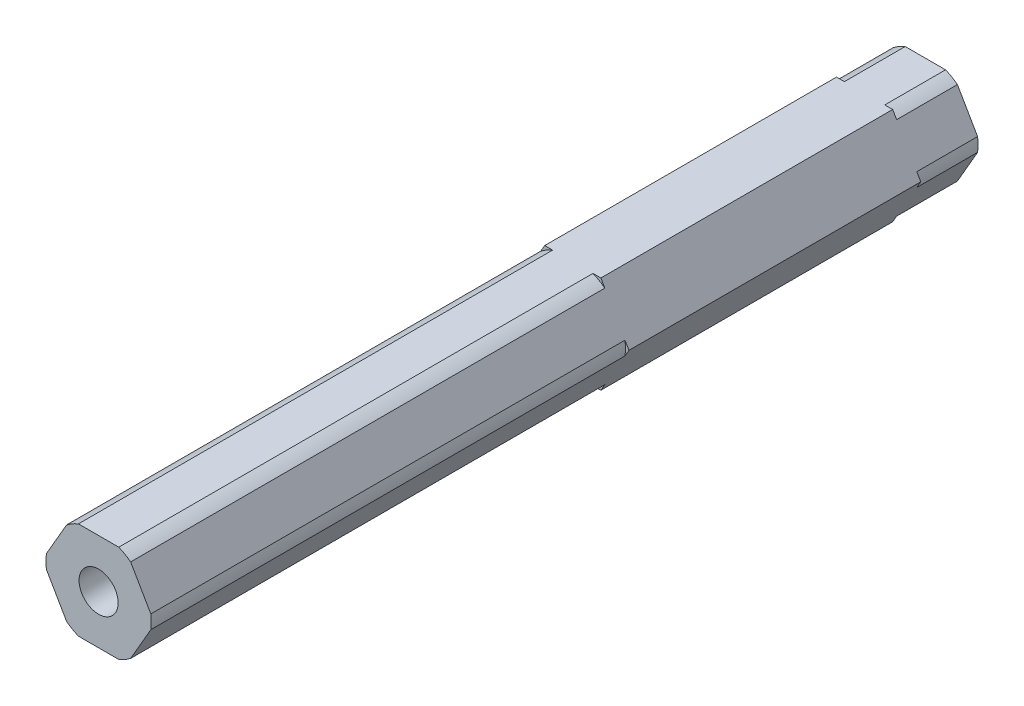
from build123d import *

# Parameters (mm, degrees)
BOSS_EXTRUDE1_DEPTH         = 19.05
BOSS_EXTRUDE2_DEPTH         = 7.9375
BOSS_EXTRUDE3_DEPTH         = 53.975
SKETCH6_R                   = 3.175
CUT_EXTRUDE1_DEPTH          = 11.811
F_10_32_TAPPED_HOLE1_D      = 4.0386
F_10_32_TAPPED_HOLE1_DEPTH  = 12.0396
F_10_32_TAPPED_HOLE1_TIP    = 1.213317848
F_1_4_20_TAPPED_HOLE1_D     = 5.1054
F_1_4_20_TAPPED_HOLE1_DEPTH = 19.05
F_1_4_20_TAPPED_HOLE1_TIP   = 1.533816902


with BuildPart() as part:
    # Sketch1 → Boss-Extrude1 (new body, symmetric)
    with BuildSketch(Plane.XY):
        Polygon((-7.332348419, 0), (-3.666174209, -6.35), (3.666174209, -6.35), (7.332348419, 0), (3.666174209, 6.35), (-3.666174209, 6.35), align=None)
    extrude(amount=BOSS_EXTRUDE1_DEPTH, both=True)

    # Sketch2 → Boss-Extrude2 (add)
    with BuildSketch(Plane.XY.offset(19.05)):
        with BuildLine():
            Line((6.816751826, 0.893039494), (4.181770802, 5.456960506))
            ThreePointArc((4.181770802, 5.456960506), (3.4375, 5.953924651), (2.634981025, 6.35))
            Line((2.634981025, 6.35), (-2.634981025, 6.35))
            ThreePointArc((-2.634981025, 6.35), (-3.4375, 5.953924651), (-4.181770802, 5.456960506))
            Line((-4.181770802, 5.456960506), (-6.816751826, 0.893039494))
            ThreePointArc((-6.816751826, 0.893039494), (-6.875, 0), (-6.816751826, -0.893039494))
            Line((-6.816751826, -0.893039494), (-4.181770802, -5.456960506))
            ThreePointArc((-4.181770802, -5.456960506), (-3.4375, -5.953924651), (-2.634981025, -6.35))
            Line((-2.634981025, -6.35), (2.634981025, -6.35))
            ThreePointArc((2.634981025, -6.35), (3.4375, -5.953924651), (4.181770802, -5.456960506))
            Line((4.181770802, -5.456960506), (6.816751826, -0.893039494))
            ThreePointArc((6.816751826, -0.893039494), (6.875, 0), (6.816751826, 0.893039494))
        make_face()
    boss_extrude2 = extrude(amount=BOSS_EXTRUDE2_DEPTH)

    # Mirror1: Boss-Extrude2 across plane
    add(boss_extrude2.mirror(Plane.XY))

    # Sketch3 → Boss-Extrude3 (add)
    with BuildSketch(Plane.XY.offset(26.9875)):
        with BuildLine():
            Line((6.816751826, 0.893039494), (4.181770802, 5.456960506))
            ThreePointArc((4.181770802, 5.456960506), (3.4375, 5.953924651), (2.634981025, 6.35))
            Line((2.634981025, 6.35), (-2.634981025, 6.35))
            ThreePointArc((-2.634981025, 6.35), (-3.4375, 5.953924651), (-4.181770802, 5.456960506))
            Line((-4.181770802, 5.456960506), (-6.816751826, 0.893039494))
            ThreePointArc((-6.816751826, 0.893039494), (-6.875, 0), (-6.816751826, -0.893039494))
            Line((-6.816751826, -0.893039494), (-4.181770802, -5.456960506))
            ThreePointArc((-4.181770802, -5.456960506), (-3.4375, -5.953924651), (-2.634981025, -6.35))
            Line((-2.634981025, -6.35), (2.634981025, -6.35))
            ThreePointArc((2.634981025, -6.35), (3.4375, -5.953924651), (4.181770802, -5.456960506))
            Line((4.181770802, -5.456960506), (6.816751826, -0.893039494))
            ThreePointArc((6.816751826, -0.893039494), (6.875, 0), (6.816751826, 0.893039494))
        make_face()
    extrude(amount=BOSS_EXTRUDE3_DEPTH)

    # Sketch6 → Cut-Extrude1 (cut)
    with BuildSketch(Plane(origin=(0, 0, -26.9875), x_dir=(-1, 0, 0), z_dir=(0, 0, -1))):
        Circle(SKETCH6_R)
    extrude(amount=-CUT_EXTRUDE1_DEPTH, mode=Mode.SUBTRACT)

    # #10-32 Tapped Hole1
    with Locations(Plane(origin=(0, 0, -15.1765), x_dir=(-1, 0, 0), z_dir=(0, 0, -1))):
        with Locations((0, 0)):
            Hole(F_10_32_TAPPED_HOLE1_D / 2, depth=F_10_32_TAPPED_HOLE1_DEPTH)
            with Locations((0, 0, -(F_10_32_TAPPED_HOLE1_DEPTH + F_10_32_TAPPED_HOLE1_TIP / 2))):  # 118° drill point
                Cone(0, F_10_32_TAPPED_HOLE1_D / 2, F_10_32_TAPPED_HOLE1_TIP, mode=Mode.SUBTRACT)

    # 1/4-20 Tapped Hole1
    with Locations(Plane.XY.offset(80.9625)):
        with Locations((0, 0)):
            Hole(F_1_4_20_TAPPED_HOLE1_D / 2, depth=F_1_4_20_TAPPED_HOLE1_DEPTH)
            with Locations((0, 0, -(F_1_4_20_TAPPED_HOLE1_DEPTH + F_1_4_20_TAPPED_HOLE1_TIP / 2))):  # 118° drill point
                Cone(0, F_1_4_20_TAPPED_HOLE1_D / 2, F_1_4_20_TAPPED_HOLE1_TIP, mode=Mode.SUBTRACT)


solid = part.part
